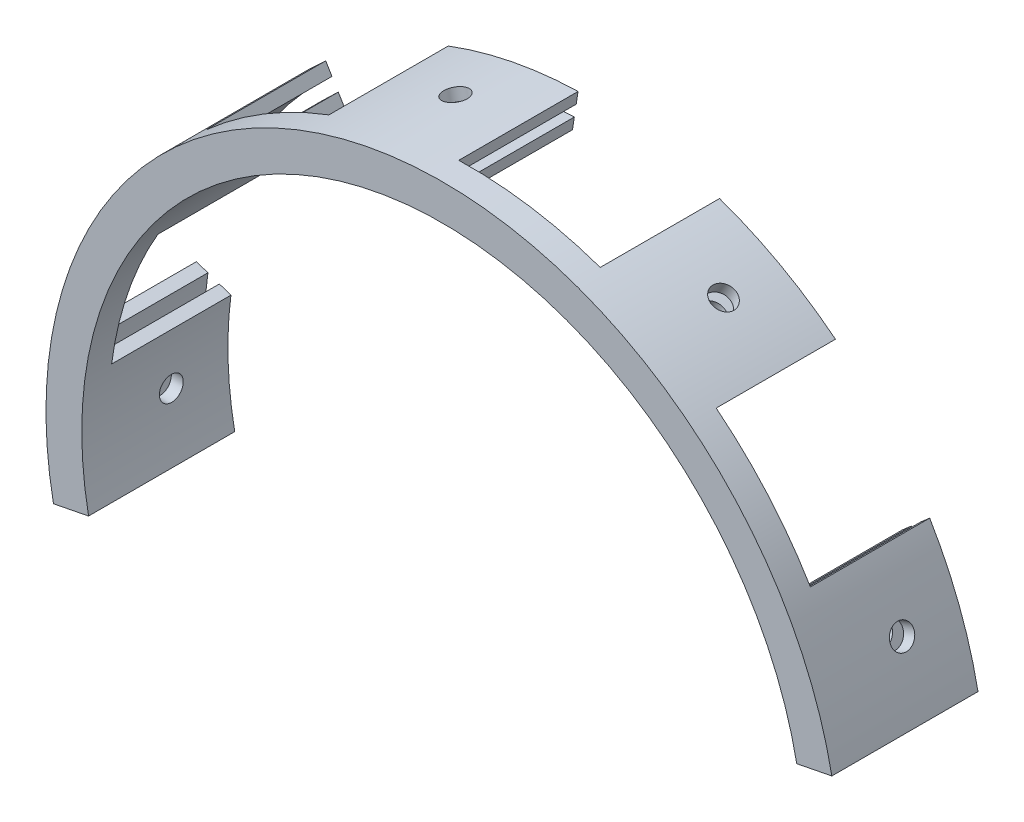
from build123d import *

# Parameters (mm, degrees)
BOSS_EXTRUDE1_DEPTH   = 22
BOSS_EXTRUDE1_2_DEPTH = 22
BOSS_EXTRUDE2_DEPTH   = 2.5
CUT_EXTRUDE2_START    = -128.160746384
SKETCH7_R             = 2
CUT_EXTRUDE2_DEPTH    = 153.505282119
CIRPATTERN1_COUNT     = 5
CIRPATTERN1_ANGLE     = 160
CUT_EXTRUDE3_START    = -120.036136555
SKETCH8_W             = 20
SKETCH8_H             = 24
CUT_EXTRUDE3_DEPTH    = 153.423846536
CIRPATTERN2_COUNT     = 4
CIRPATTERN2_ANGLE     = 120


with BuildPart() as part:
    # Sketch1 → Boss-Extrude1 (new body)
    with BuildSketch(Plane.XY):
        with BuildLine():
            Line((63.282138516, 12.474812415), (65.24437537, 12.861628304))
            ThreePointArc((65.24437537, 12.861628304), (-12.861628304, 65.24437537), (-65.24437537, -12.861628304))
            Line((-65.24437537, -12.861628304), (-63.282138516, -12.474812415))
            ThreePointArc((-63.282138516, -12.474812415), (-12.474812415, 63.282138516), (63.282138516, 12.474812415))
        make_face()
    extrude(amount=-BOSS_EXTRUDE1_DEPTH)



with BuildPart() as body_2:
    # Sketch1 → Boss-Extrude1 2 (new body)
    with BuildSketch(Plane.XY):
        with BuildLine():
            Line((61.319901663, 12.087996526), (59.35766481, 11.701180637))
            ThreePointArc((59.35766481, 11.701180637), (-11.701180637, 59.35766481), (-59.35766481, -11.701180637))
            Line((-59.35766481, -11.701180637), (-61.319901663, -12.087996526))
            ThreePointArc((-61.319901663, -12.087996526), (-12.087996526, 61.319901663), (61.319901663, 12.087996526))
        make_face()
    extrude(amount=-BOSS_EXTRUDE1_2_DEPTH)


with BuildPart() as part_1:
    add(part.part)

    add(body_2.part)  # Boss-Extrude2 merges body 2
    # Sketch2 → Boss-Extrude2 (add)
    with BuildSketch(Plane.XY):
        with BuildLine():
            Line((-65.24437537, -12.861628304), (-59.35766481, -11.701180637))
            ThreePointArc((-59.35766481, -11.701180637), (-11.701180637, 59.35766481), (59.35766481, 11.701180637))
            Line((59.35766481, 11.701180637), (65.24437537, 12.861628304))
            ThreePointArc((65.24437537, 12.861628304), (-12.861628304, 65.24437537), (-65.24437537, -12.861628304))
        make_face()
    extrude(amount=BOSS_EXTRUDE2_DEPTH)

    # Sketch7 → Cut-Extrude2 (cut)
    with BuildSketch(Plane(origin=(56.423999811, 21.830763736, 2.5), x_dir=(0, 0, -1), z_dir=(0.932628096, 0.36083907, 0)).offset(CUT_EXTRUDE2_START)):
        with Locations((15, 0)):
            Circle(SKETCH7_R)
    cut_extrude2 = extrude(amount=CUT_EXTRUDE2_DEPTH, mode=Mode.SUBTRACT)

    # CirPattern1: Cut-Extrude2 ×5 about axis
    cirpattern1_axis = Axis((0, 0, 0), (0, 0, 1))
    for i in range(1, CIRPATTERN1_COUNT):
        add(cut_extrude2.rotate(cirpattern1_axis, i * CIRPATTERN1_ANGLE / (CIRPATTERN1_COUNT - 1)), mode=Mode.SUBTRACT)

    # Sketch8 → Cut-Extrude3 (cut)
    with BuildSketch(Plane(origin=(45.554655316, 39.812352091, 2.5), x_dir=(0, 0, -1), z_dir=(0.752969509, 0.658055406, 0)).offset(CUT_EXTRUDE3_START)):
        with Locations((14.5, 0)):
            Rectangle(SKETCH8_W, SKETCH8_H)
    cut_extrude3 = extrude(amount=CUT_EXTRUDE3_DEPTH, mode=Mode.SUBTRACT)

    # CirPattern2: Cut-Extrude3 ×4 about axis
    cirpattern2_axis = Axis((0, 0, 0), (0, 0, 1))
    for i in range(1, CIRPATTERN2_COUNT):
        add(cut_extrude3.rotate(cirpattern2_axis, i * CIRPATTERN2_ANGLE / (CIRPATTERN2_COUNT - 1)), mode=Mode.SUBTRACT)


solid = part_1.part
